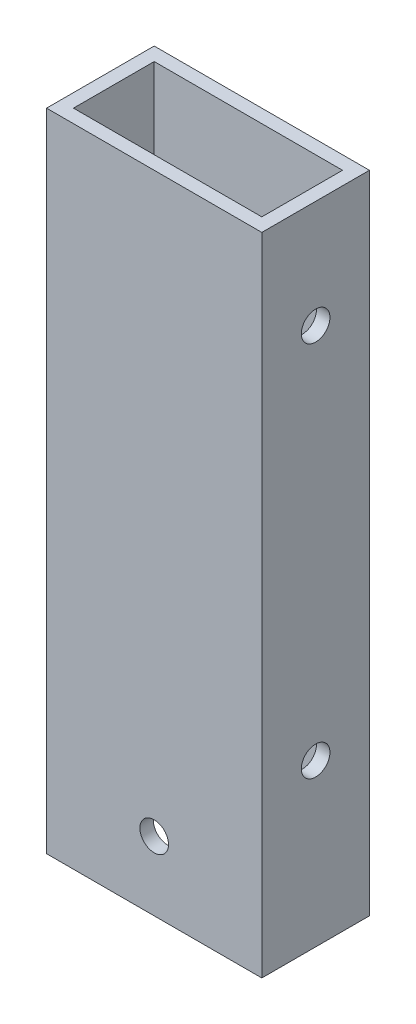
from build123d import *

# Parameters (mm, degrees)
SKETCH1_W           = 50.8
SKETCH1_H           = 25.4
SKETCH1_W_2         = 44.45
SKETCH1_H_2         = 19.05
BOSS_EXTRUDE1_DEPTH = 152.4
SKETCH2_R           = 3.3782
CUT_EXTRUDE1_DEPTH  = 51.8
SKETCH3_R           = 3.3782
CUT_EXTRUDE2_DEPTH  = 26.4


with BuildPart() as part:
    # Sketch1 → Boss-Extrude1 (new body)
    with BuildSketch(Plane(origin=(0, 0, 0), x_dir=(1, 0, 0), z_dir=(0, 1, 0))):
        with Locations((25.4, 12.7)):
            Rectangle(SKETCH1_W, SKETCH1_H)
        with Locations((25.4, 12.7)):
            Rectangle(SKETCH1_W_2, SKETCH1_H_2, mode=Mode.SUBTRACT)
    extrude(amount=BOSS_EXTRUDE1_DEPTH)

    # Sketch2 → Cut-Extrude1 (cut, through all)
    with BuildSketch(Plane.ZY):
        with Locations((-12.7, 127)):
            Circle(SKETCH2_R)
        with Locations((-12.7, 38.1)):
            Circle(SKETCH2_R)
    extrude(amount=-CUT_EXTRUDE1_DEPTH, mode=Mode.SUBTRACT)

    # Sketch3 → Cut-Extrude2 (cut, through all)
    with BuildSketch(Plane(origin=(0, 0, -25.4), x_dir=(-1, 0, 0), z_dir=(0, 0, -1))):
        with Locations((-25.4, 16.2687)):
            Circle(SKETCH3_R)
    extrude(amount=-CUT_EXTRUDE2_DEPTH, mode=Mode.SUBTRACT)


solid = part.part
